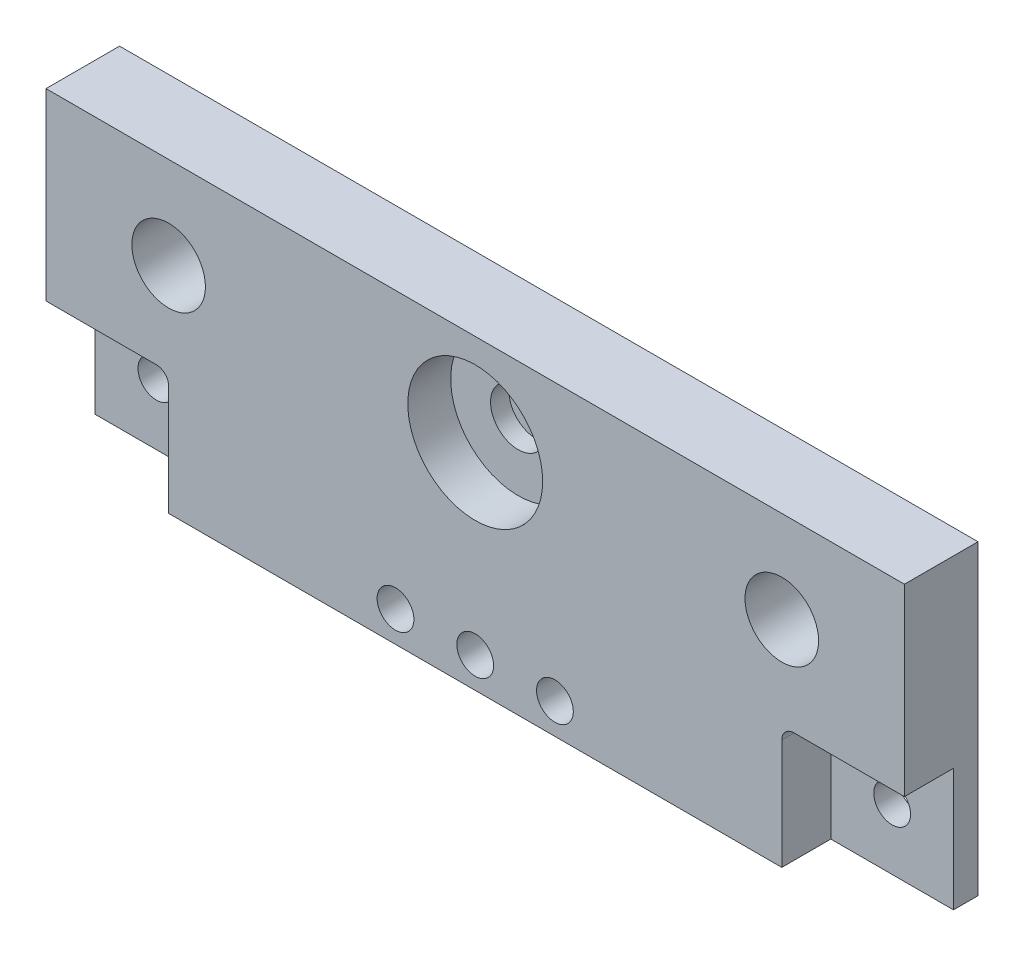
from build123d import *

# Parameters (mm, degrees)
ESQUISSE1_W             = 140
ESQUISSE1_H             = 30
ESQUISSE1_R             = 11
ESQUISSE1_R_2           = 6
EXTRUSION1_DEPTH        = 8
ESQUISSE2_W             = 140
ESQUISSE2_H             = 50
BOSS_EXTRU_1_DEPTH      = 4
ESQUISSE3_R             = 3
ENL_V_MAT_EXTRU_1_DEPTH = 13
ESQUISSE4_R             = 11
ENL_V_MAT_EXTRU_2_DEPTH = 2
ESQUISSE5_W             = 100
ESQUISSE5_H             = 20
BOSS_EXTRU_2_DEPTH      = 8
ESQUISSE6_R             = 3
ENL_V_MAT_EXTRU_3_DEPTH = 8
ESQUISSE8_R             = 6
ENL_V_MAT_EXTRU_4_DEPTH = 2
ESQUISSE9_R             = 11
ESQUISSE9_R_2           = 4.5
BOSS_EXTRU_3_DEPTH      = 3
ESQUISSE10_R            = 3
ENL_V_MAT_EXTRU_5_DEPTH = 13
CONG_1_R                = 2
CONG_2_R                = 2


with BuildPart() as part:
    # Esquisse1 → Extrusion1 (new body)
    with BuildSketch(Plane.XY):
        with Locations((9.95634141, -28.081325038)):
            Rectangle(ESQUISSE1_W, ESQUISSE1_H)
        with Locations((9.95634141, -28.081325038)):
            Circle(ESQUISSE1_R, mode=Mode.SUBTRACT)
        with Locations((-40.04365859, -28.081325038)):
            Circle(ESQUISSE1_R_2, mode=Mode.SUBTRACT)
        with Locations((59.95634141, -28.081325038)):
            Circle(ESQUISSE1_R_2, mode=Mode.SUBTRACT)
    extrude(amount=EXTRUSION1_DEPTH)

    # Esquisse2 → Boss.-Extru.1 (add)
    with BuildSketch(Plane(origin=(0, 0, 0), x_dir=(-1, 0, 0), z_dir=(0, 0, -1))):
        with Locations((-9.95634141, -38.081325038)):
            Rectangle(ESQUISSE2_W, ESQUISSE2_H)
    extrude(amount=BOSS_EXTRU_1_DEPTH)

    # Esquisse3 → Enlèv. mat.-Extru.1 (cut, through all)
    with BuildSketch(Plane(origin=(0, 0, -4), x_dir=(-1, 0, 0), z_dir=(0, 0, -1))):
        with Locations((-69.95634141, -53.081325038)):
            Circle(ESQUISSE3_R)
        with Locations((50.04365859, -53.081325038)):
            Circle(ESQUISSE3_R)
    extrude(amount=-ENL_V_MAT_EXTRU_1_DEPTH, mode=Mode.SUBTRACT)

    # Esquisse4 → Enlèv. mat.-Extru.2 (cut)
    with BuildSketch(Plane.XY):
        with Locations((9.95634141, -28.081325038)):
            Circle(ESQUISSE4_R)
    extrude(amount=-ENL_V_MAT_EXTRU_2_DEPTH, mode=Mode.SUBTRACT)

    # Esquisse5 → Boss.-Extru.2 (add)
    with BuildSketch(Plane.XY):
        with Locations((9.95634141, -53.081325038)):
            Rectangle(ESQUISSE5_W, ESQUISSE5_H)
    extrude(amount=BOSS_EXTRU_2_DEPTH)

    # Esquisse6 → Enlèv. mat.-Extru.3 (cut)
    with BuildSketch(Plane.XY.offset(8)):
        with Locations((22.95634141, -58.081325038)):
            Circle(ESQUISSE6_R)
        with Locations((-3.04365859, -58.081325038)):
            Circle(ESQUISSE6_R)
    extrude(amount=-ENL_V_MAT_EXTRU_3_DEPTH, mode=Mode.SUBTRACT)

    # Esquisse8 → Enlèv. mat.-Extru.4 (cut)
    with BuildSketch(Plane.XY):
        with Locations((-40.04365859, -28.081325038)):
            Circle(ESQUISSE8_R)
        with Locations((59.95634141, -28.081325038)):
            Circle(ESQUISSE8_R)
    extrude(amount=-ENL_V_MAT_EXTRU_4_DEPTH, mode=Mode.SUBTRACT)

    # Esquisse9 → Boss.-Extru.3 (add)
    with BuildSketch(Plane.XY.offset(-2)):
        with Locations((9.95634141, -28.081325038)):
            Circle(ESQUISSE9_R)
        with Locations((9.95634141, -28.081325038)):
            Circle(ESQUISSE9_R_2, mode=Mode.SUBTRACT)
    extrude(amount=BOSS_EXTRU_3_DEPTH)

    # Esquisse10 → Enlèv. mat.-Extru.5 (cut, through all)
    with BuildSketch(Plane.XY.offset(8)):
        with Locations((9.95634141, -58.081325038)):
            Circle(ESQUISSE10_R)
    extrude(amount=-ENL_V_MAT_EXTRU_5_DEPTH, mode=Mode.SUBTRACT)

    # Congé1
    cong_1_edges = [part.edges().sort_by_distance(p)[0] for p in [
        (-40.04365859, -43.081325038, 4),
    ]]
    fillet(cong_1_edges, radius=CONG_1_R)

    # Congé2
    cong_2_edges = [part.edges().sort_by_distance(p)[0] for p in [
        (59.95634141, -43.081325038, 4),
    ]]
    fillet(cong_2_edges, radius=CONG_2_R)


solid = part.part
